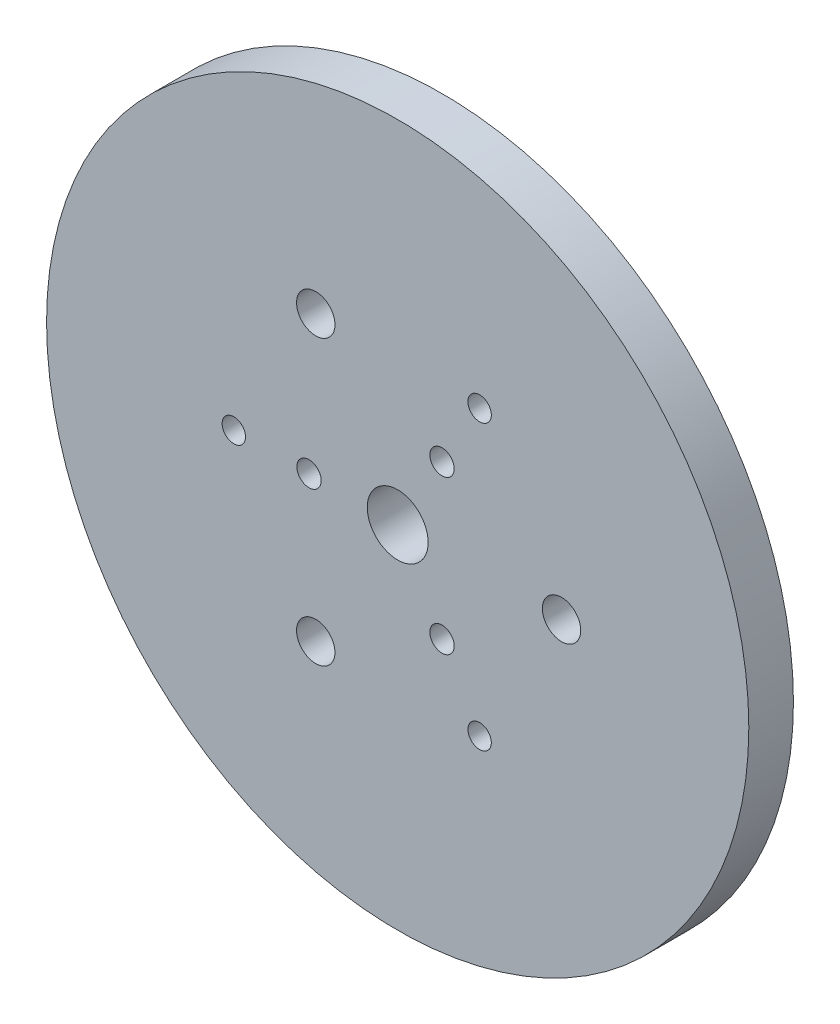
from build123d import *

# Parameters (mm, degrees)
CROQUIS1_R              = 75
SALIENTE_EXTRUIR1_DEPTH = 9.53
CORTAR_EXTRUIR1_REACH   = 11.53
CROQUIS2_R              = 4.1
CORTAR_EXTRUIR2_REACH   = 11.53
CROQUIS3_R              = 6.5
CORTAR_EXTRUIR3_REACH   = 11.53
CROQUIS4_R              = 2.6
CORTAR_EXTRUIR4_REACH   = 11.53
CROQUIS5_R              = 2.5


with BuildPart() as part:
    # Croquis1 → Saliente-Extruir1 (new body)
    with BuildSketch(Plane.XY):
        Circle(CROQUIS1_R)
    extrude(amount=SALIENTE_EXTRUIR1_DEPTH)

    # Croquis2 → Cortar-Extruir1 (cut, up to next)
    with BuildSketch(Plane(origin=(0, 0, 0), x_dir=(-1, 0, 0), z_dir=(0, 0, -1)), mode=Mode.PRIVATE) as cortar_extruir1_sk1:
        with Locations((-35, 0)):
            Circle(CROQUIS2_R)
    cortar_extruir1_tool1 = extrude(cortar_extruir1_sk1.sketch, amount=-CORTAR_EXTRUIR1_REACH, mode=Mode.PRIVATE) & part.part
    add(cortar_extruir1_tool1.solids().sort_by_distance((35, 0, 0))[0], mode=Mode.SUBTRACT)
    # Croquis2 → Cortar-Extruir1 (cut, up to next)
    with BuildSketch(Plane(origin=(0, 0, 0), x_dir=(-1, 0, 0), z_dir=(0, 0, -1)), mode=Mode.PRIVATE) as cortar_extruir1_sk2:
        with Locations((17.5, 30.310889132)):
            Circle(CROQUIS2_R)
    cortar_extruir1_tool2 = extrude(cortar_extruir1_sk2.sketch, amount=-CORTAR_EXTRUIR1_REACH, mode=Mode.PRIVATE) & part.part
    add(cortar_extruir1_tool2.solids().sort_by_distance((-17.5, 30.310889, 0))[0], mode=Mode.SUBTRACT)
    # Croquis2 → Cortar-Extruir1 (cut, up to next)
    with BuildSketch(Plane(origin=(0, 0, 0), x_dir=(-1, 0, 0), z_dir=(0, 0, -1)), mode=Mode.PRIVATE) as cortar_extruir1_sk3:
        with Locations((17.5, -30.310889132)):
            Circle(CROQUIS2_R)
    cortar_extruir1_tool3 = extrude(cortar_extruir1_sk3.sketch, amount=-CORTAR_EXTRUIR1_REACH, mode=Mode.PRIVATE) & part.part
    add(cortar_extruir1_tool3.solids().sort_by_distance((-17.5, -30.310889, 0))[0], mode=Mode.SUBTRACT)

    # Croquis3 → Cortar-Extruir2 (cut, up to next)
    with BuildSketch(Plane(origin=(0, 0, 0), x_dir=(-1, 0, 0), z_dir=(0, 0, -1)), mode=Mode.PRIVATE) as cortar_extruir2_sk1:
        Circle(CROQUIS3_R)
    cortar_extruir2_tool1 = extrude(cortar_extruir2_sk1.sketch, amount=-CORTAR_EXTRUIR2_REACH, mode=Mode.PRIVATE) & part.part
    add(cortar_extruir2_tool1.solids().sort_by_distance((0, 0, 0))[0], mode=Mode.SUBTRACT)

    # Croquis4 → Cortar-Extruir3 (cut, up to next)
    with BuildSketch(Plane.XY.offset(9.53), mode=Mode.PRIVATE) as cortar_extruir3_sk1:
        with Locations((-18.937088829, 0)):
            Circle(CROQUIS4_R)
    cortar_extruir3_tool1 = extrude(cortar_extruir3_sk1.sketch, amount=-CORTAR_EXTRUIR3_REACH, mode=Mode.PRIVATE) & part.part
    add(cortar_extruir3_tool1.solids().sort_by_distance((-18.937089, 0, 9.53))[0], mode=Mode.SUBTRACT)
    # Croquis4 → Cortar-Extruir3 (cut, up to next)
    with BuildSketch(Plane.XY.offset(9.53), mode=Mode.PRIVATE) as cortar_extruir3_sk2:
        with Locations((9.468544415, 16.4)):
            Circle(CROQUIS4_R)
    cortar_extruir3_tool2 = extrude(cortar_extruir3_sk2.sketch, amount=-CORTAR_EXTRUIR3_REACH, mode=Mode.PRIVATE) & part.part
    add(cortar_extruir3_tool2.solids().sort_by_distance((9.468544, 16.4, 9.53))[0], mode=Mode.SUBTRACT)
    # Croquis4 → Cortar-Extruir3 (cut, up to next)
    with BuildSketch(Plane.XY.offset(9.53), mode=Mode.PRIVATE) as cortar_extruir3_sk3:
        with Locations((9.468544415, -16.4)):
            Circle(CROQUIS4_R)
    cortar_extruir3_tool3 = extrude(cortar_extruir3_sk3.sketch, amount=-CORTAR_EXTRUIR3_REACH, mode=Mode.PRIVATE) & part.part
    add(cortar_extruir3_tool3.solids().sort_by_distance((9.468544, -16.4, 9.53))[0], mode=Mode.SUBTRACT)

    # Croquis5 → Cortar-Extruir4 (cut, up to next)
    with BuildSketch(Plane.XY.offset(9.53), mode=Mode.PRIVATE) as cortar_extruir4_sk1:
        with Locations((-35, 0)):
            Circle(CROQUIS5_R)
    cortar_extruir4_tool1 = extrude(cortar_extruir4_sk1.sketch, amount=-CORTAR_EXTRUIR4_REACH, mode=Mode.PRIVATE) & part.part
    add(cortar_extruir4_tool1.solids().sort_by_distance((-35, 0, 9.53))[0], mode=Mode.SUBTRACT)
    # Croquis5 → Cortar-Extruir4 (cut, up to next)
    with BuildSketch(Plane.XY.offset(9.53), mode=Mode.PRIVATE) as cortar_extruir4_sk2:
        with Locations((17.5, 30.310889132)):
            Circle(CROQUIS5_R)
    cortar_extruir4_tool2 = extrude(cortar_extruir4_sk2.sketch, amount=-CORTAR_EXTRUIR4_REACH, mode=Mode.PRIVATE) & part.part
    add(cortar_extruir4_tool2.solids().sort_by_distance((17.5, 30.310889, 9.53))[0], mode=Mode.SUBTRACT)
    # Croquis5 → Cortar-Extruir4 (cut, up to next)
    with BuildSketch(Plane.XY.offset(9.53), mode=Mode.PRIVATE) as cortar_extruir4_sk3:
        with Locations((17.5, -30.310889132)):
            Circle(CROQUIS5_R)
    cortar_extruir4_tool3 = extrude(cortar_extruir4_sk3.sketch, amount=-CORTAR_EXTRUIR4_REACH, mode=Mode.PRIVATE) & part.part
    add(cortar_extruir4_tool3.solids().sort_by_distance((17.5, -30.310889, 9.53))[0], mode=Mode.SUBTRACT)


solid = part.part
